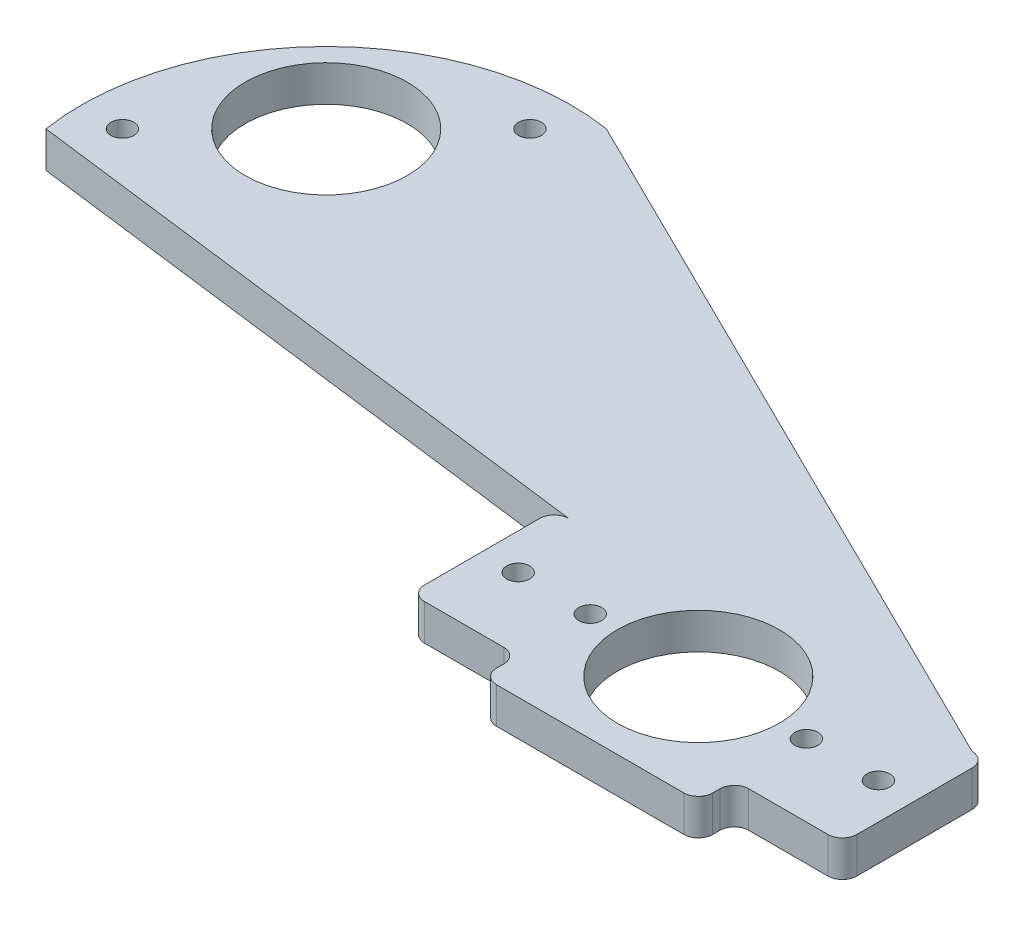
from build123d import *

# Parameters (mm, degrees)
SKETCH1_R           = 14.2875
SKETCH1_R_2         = 2.0193
BOSS_EXTRUDE1_DEPTH = 6.35
SKETCH3_R           = 2.0193
SKETCH3_R_2         = 14.2875
BOSS_EXTRUDE3_DEPTH = 6.35


with BuildPart() as part:
    # Sketch1 → Boss-Extrude1 (new body)
    with BuildSketch(Plane(origin=(0, 0, 0), x_dir=(1, 0, 0), z_dir=(0, 1, 0))):
        with BuildLine():
            Line((-16.51, -19.05), (16.51, -19.05))
            ThreePointArc((16.51, -19.05), (18.306051224, -18.306051224), (19.05, -16.51))
            Line((19.05, -16.51), (19.05, -15.24))
            ThreePointArc((19.05, -15.24), (19.793948776, -13.443948776), (21.59, -12.7))
            Line((21.59, -12.7), (35.56, -12.7))
            ThreePointArc((35.56, -12.7), (37.356051224, -11.956051224), (38.1, -10.16))
            Line((38.1, -10.16), (38.1, 10.16))
            ThreePointArc((38.1, 10.16), (37.356051224, 11.956051224), (35.56, 12.7))
            Line((35.56, 12.7), (21.59, 12.7))
            ThreePointArc((21.59, 12.7), (19.793948776, 13.443948776), (19.05, 15.24))
            Line((19.05, 15.24), (19.05, 16.51))
            ThreePointArc((19.05, 16.51), (18.306051224, 18.306051224), (16.51, 19.05))
            Line((16.51, 19.05), (-16.51, 19.05))
            ThreePointArc((-16.51, 19.05), (-18.306051224, 18.306051224), (-19.05, 16.51))
            Line((-19.05, 16.51), (-19.05, 15.24))
            ThreePointArc((-19.05, 15.24), (-19.793948776, 13.443948776), (-21.59, 12.7))
            Line((-21.59, 12.7), (-35.56, 12.7))
            ThreePointArc((-35.56, 12.7), (-37.356051224, 11.956051224), (-38.1, 10.16))
            Line((-38.1, 10.16), (-38.1, -10.16))
            ThreePointArc((-38.1, -10.16), (-37.356051224, -11.956051224), (-35.56, -12.7))
            Line((-35.56, -12.7), (-21.59, -12.7))
            ThreePointArc((-21.59, -12.7), (-19.793948776, -13.443948776), (-19.05, -15.24))
            Line((-19.05, -15.24), (-19.05, -16.51))
            ThreePointArc((-19.05, -16.51), (-18.306051224, -18.306051224), (-16.51, -19.05))
        make_face()
        Circle(SKETCH1_R, mode=Mode.SUBTRACT)
        with Locations((-31.75, 0)):
            Circle(SKETCH1_R_2, mode=Mode.SUBTRACT)
        with Locations((-19.05, 0)):
            Circle(SKETCH1_R_2, mode=Mode.SUBTRACT)
        with Locations((19.05, 0)):
            Circle(SKETCH1_R_2, mode=Mode.SUBTRACT)
        with Locations((31.75, 0)):
            Circle(SKETCH1_R_2, mode=Mode.SUBTRACT)
    extrude(amount=BOSS_EXTRUDE1_DEPTH)

    # Sketch3 → Boss-Extrude3 (add)
    with BuildSketch(Plane(origin=(0, 6.35, 0), x_dir=(1, 0, 0), z_dir=(0, 1, 0))):
        with BuildLine():
            ThreePointArc((-91.701718319, 75.495704333), (-128.973082608, 63.375659956), (-141.093126985, 26.104295667))
            Line((-141.093126985, 26.104295667), (-35.56, 12.7))
            Line((-35.56, 12.7), (-21.59, 12.7))
            ThreePointArc((-21.59, 12.7), (-19.793948776, 13.443948776), (-19.05, 15.24))
            Line((-19.05, 15.24), (-19.05, 16.51))
            ThreePointArc((-19.05, 16.51), (-18.306051224, 18.306051224), (-16.51, 19.05))
            Line((-16.51, 19.05), (16.51, 19.05))
            ThreePointArc((16.51, 19.05), (18.306051224, 18.306051224), (19.05, 16.51))
            Line((19.05, 16.51), (19.05, 15.24))
            ThreePointArc((19.05, 15.24), (19.793948776, 13.443948776), (21.59, 12.7))
            Line((21.59, 12.7), (35.56, 12.7))
            Line((35.56, 12.7), (-91.701718319, 75.495704333))
        make_face()
        with Locations((-134.357934894, 32.839487758)):
            Circle(SKETCH3_R, mode=Mode.SUBTRACT)
        with Locations((-116.397422652, 50.8)):
            Circle(SKETCH3_R_2, mode=Mode.SUBTRACT)
        with Locations((-98.43691041, 68.760512242)):
            Circle(SKETCH3_R, mode=Mode.SUBTRACT)
    extrude(amount=-BOSS_EXTRUDE3_DEPTH)


solid = part.part
